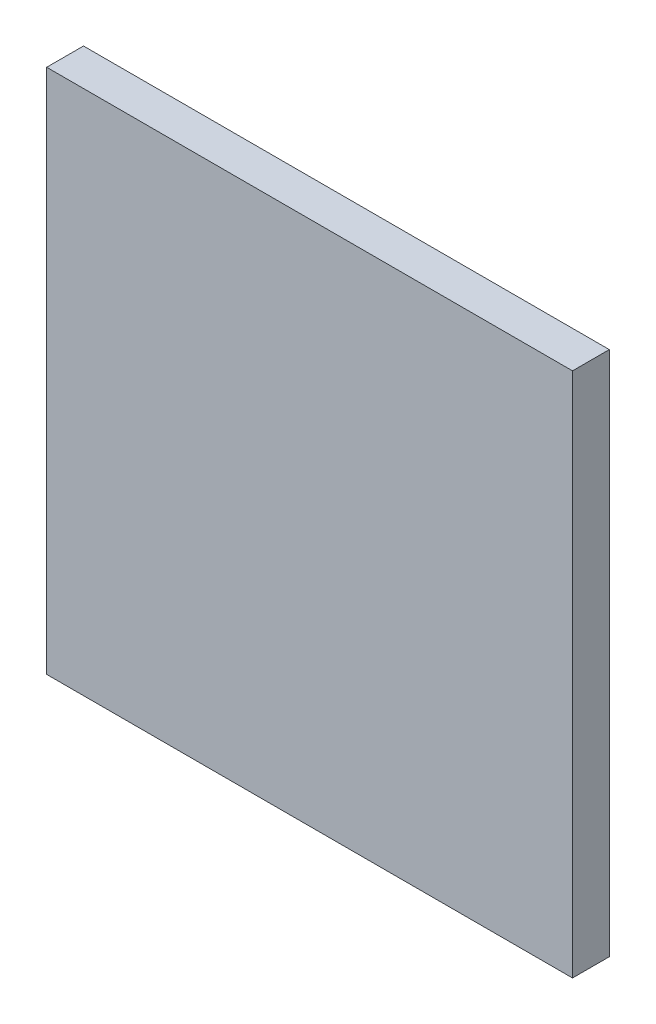
from build123d import *

# Parameters (mm, degrees)
SKETCH_1_W      = 50
SKETCH_1_H      = 50
EXTRUDE_1_DEPTH = 3.5


with BuildPart() as part:
    # Эскиз1 → Бобышка-Вытянуть1 (new body)
    with BuildSketch(Plane.XY):
        Rectangle(SKETCH_1_W, SKETCH_1_H)
    extrude(amount=EXTRUDE_1_DEPTH)


solid = part.part
